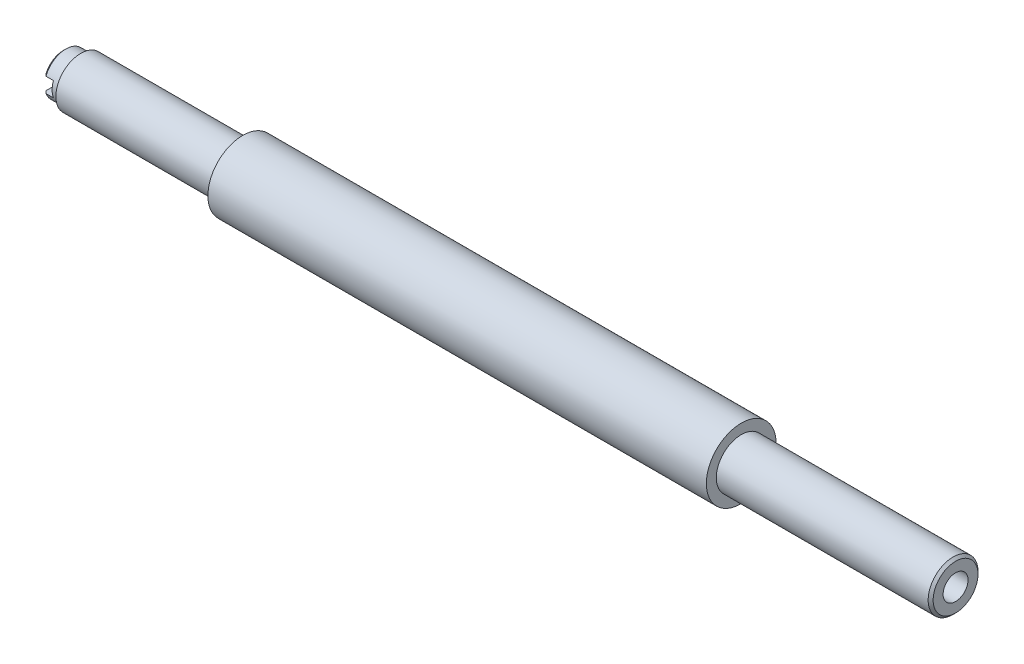
from build123d import *

# Parameters (mm, degrees)
ESQUISSE1_R             = 7
EXTRUSION1_DEPTH        = 100
ESQUISSE2_R             = 5
ESQUISSE2_R_2           = 2.5
EXTRUSION2_DEPTH        = 143
EXTRUSION2_DEPTH_BACK   = 36
ESQUISSE3_OUTSIDE_W     = 52.018
ESQUISSE3_OUTSIDE_H     = 52.018
ESQUISSE3_OUTSIDE_R     = 4.25
ENL_V_MAT_EXTRU_1_DEPTH = 3.5
ESQUISSE4_W             = 2
ESQUISSE4_H             = 3
ENL_V_MAT_EXTRU_2_DEPTH = 8
CHANFREIN1_SIZE         = 0.5


with BuildPart() as part:
    # Esquisse1 → Extrusion1 (new body)
    with BuildSketch(Plane(origin=(0, 0, 0), x_dir=(0, 0, -1), z_dir=(1, 0, 0))):
        Circle(ESQUISSE1_R)
    extrude(amount=EXTRUSION1_DEPTH)

    # Esquisse2 → Extrusion2 (add, two sides)
    with BuildSketch(Plane(origin=(0, 0, 0), x_dir=(0, 0, -1), z_dir=(1, 0, 0))) as extrusion2_sk:
        Circle(ESQUISSE2_R)
        Circle(ESQUISSE2_R_2, mode=Mode.SUBTRACT)
    extrude(amount=EXTRUSION2_DEPTH)
    extrude(extrusion2_sk.sketch, amount=-EXTRUSION2_DEPTH_BACK)

    # Esquisse3 outside → Enlèv. mat.-Extru.1 (cut)
    with BuildSketch(Plane.ZY.offset(36)):
        Rectangle(ESQUISSE3_OUTSIDE_W, ESQUISSE3_OUTSIDE_H)
        Circle(ESQUISSE3_OUTSIDE_R, mode=Mode.SUBTRACT)
    extrude(amount=-ENL_V_MAT_EXTRU_1_DEPTH, mode=Mode.SUBTRACT)

    # Esquisse4 → Enlèv. mat.-Extru.2 (cut, through all)
    with BuildSketch(Plane.XY):
        with Locations((-35, 0)):
            Rectangle(ESQUISSE4_W, ESQUISSE4_H)
    extrude(amount=ENL_V_MAT_EXTRU_2_DEPTH, mode=Mode.SUBTRACT)

    # Chanfrein1
    chanfrein1_edges = [part.edges().sort_by_distance(p)[0] for p in [
        (-36, 0, -4.25),
        (143, 0, 5),
    ]]
    chamfer(chanfrein1_edges, length=CHANFREIN1_SIZE)


solid = part.part
